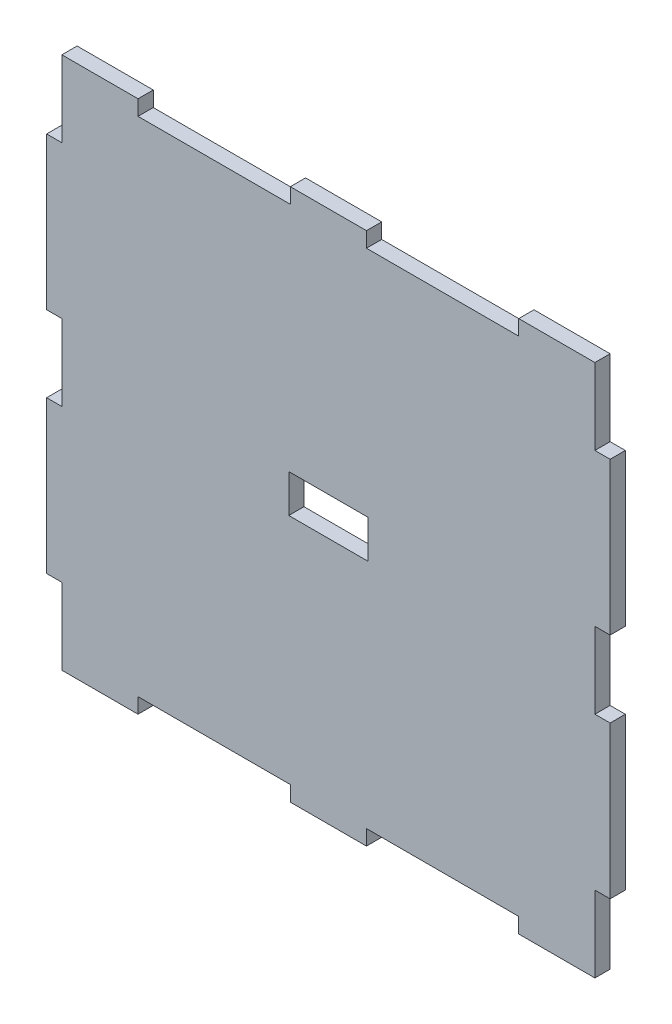
from build123d import *

# Parameters (mm, degrees)
SKETCH1_W           = 70
SKETCH1_H           = 70
BOSS_EXTRUDE1_DEPTH = 2
SKETCH2_W           = 2
SKETCH2_H           = 20
BOSS_EXTRUDE2_DEPTH = 2
SKETCH3_W           = 20
SKETCH3_H           = 2
CUT_EXTRUDE1_DEPTH  = 2
SKETCH4_W           = 10.41
SKETCH4_H           = 5
CUT_EXTRUDE2_DEPTH  = 10


with BuildPart() as part:
    # Sketch1 → Boss-Extrude1 (new body)
    with BuildSketch(Plane.XY):
        Rectangle(SKETCH1_W, SKETCH1_H)
    extrude(amount=-BOSS_EXTRUDE1_DEPTH)

    # Sketch2 → Boss-Extrude2 (add)
    with BuildSketch(Plane.XY):
        with Locations((-36, 15)):
            Rectangle(SKETCH2_W, SKETCH2_H)
        with Locations((-36, -15)):
            Rectangle(SKETCH2_W, SKETCH2_H)
        with Locations((36, -15)):
            Rectangle(SKETCH2_W, SKETCH2_H)
        with Locations((36, 15)):
            Rectangle(SKETCH2_W, SKETCH2_H)
    extrude(amount=-BOSS_EXTRUDE2_DEPTH)

    # Sketch3 → Cut-Extrude1 (cut)
    with BuildSketch(Plane.XY):
        with Locations((-15, 34)):
            Rectangle(SKETCH3_W, SKETCH3_H)
        with Locations((15, 34)):
            Rectangle(SKETCH3_W, SKETCH3_H)
        with Locations((-15, -34)):
            Rectangle(SKETCH3_W, SKETCH3_H)
        with Locations((15, -34)):
            Rectangle(SKETCH3_W, SKETCH3_H)
    extrude(amount=-CUT_EXTRUDE1_DEPTH, mode=Mode.SUBTRACT)

    # Sketch4 → Cut-Extrude2 (cut)
    with BuildSketch(Plane.XY):
        Rectangle(SKETCH4_W, SKETCH4_H)
    extrude(amount=-CUT_EXTRUDE2_DEPTH, mode=Mode.SUBTRACT)


solid = part.part
